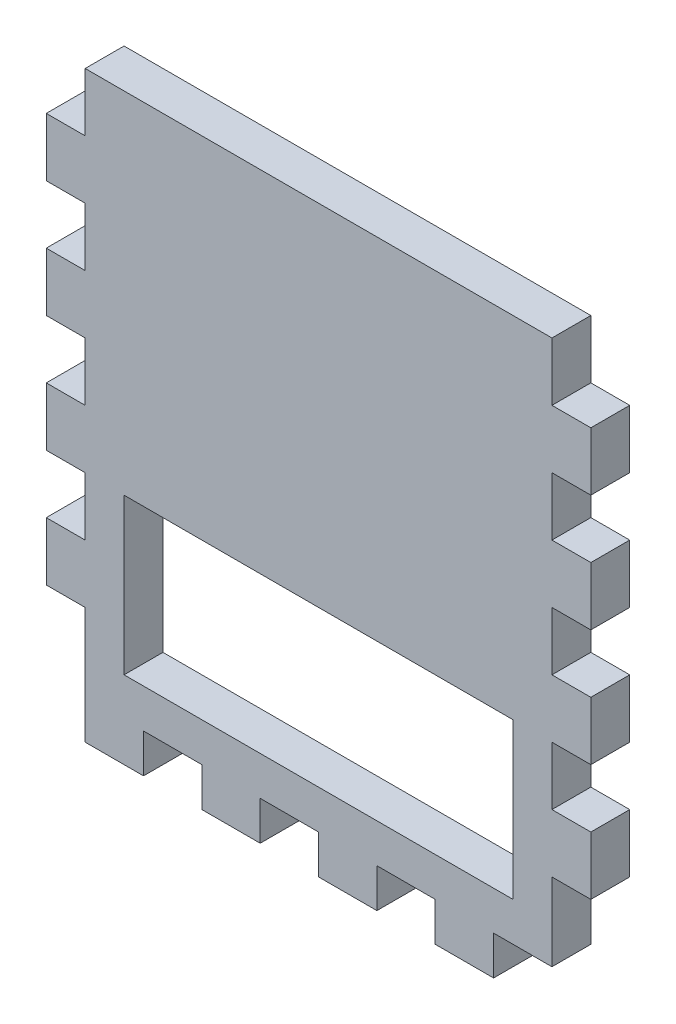
from build123d import *

# Parameters (mm, degrees)
SKETCH1_W           = 76.2
SKETCH1_H           = 88.9
SKETCH1_W_2         = 63.5
SKETCH1_H_2         = 25.4
BOSS_EXTRUDE1_DEPTH = 6.35
SKETCH2_W           = 6.35
SKETCH2_H           = 9.525
SKETCH2_W_2         = 9.525
SKETCH2_H_2         = 6.35
BOSS_EXTRUDE3_DEPTH = 6.35


with BuildPart() as part:
    # Sketch1 → Boss-Extrude1 (new body)
    with BuildSketch(Plane.XY):
        with Locations((38.1, -44.45)):
            Rectangle(SKETCH1_W, SKETCH1_H)
        with Locations((38.1, -69.85)):
            Rectangle(SKETCH1_W_2, SKETCH1_H_2, mode=Mode.SUBTRACT)
    extrude(amount=BOSS_EXTRUDE1_DEPTH)

    # Sketch2 → Boss-Extrude3 (add)
    with BuildSketch(Plane.XY.offset(6.35)):
        with Locations((-3.175, -14.2875)):
            Rectangle(SKETCH2_W, SKETCH2_H)
        with Locations((-3.175, -33.3375)):
            Rectangle(SKETCH2_W, SKETCH2_H)
        with Locations((-3.175, -52.3875)):
            Rectangle(SKETCH2_W, SKETCH2_H)
        with Locations((-3.175, -71.4375)):
            Rectangle(SKETCH2_W, SKETCH2_H)
        with Locations((4.7625, -92.075)):
            Rectangle(SKETCH2_W_2, SKETCH2_H_2)
        with Locations((23.8125, -92.075)):
            Rectangle(SKETCH2_W_2, SKETCH2_H_2)
        with Locations((79.375, -71.4375)):
            Rectangle(SKETCH2_W, SKETCH2_H)
        with Locations((79.375, -52.3875)):
            Rectangle(SKETCH2_W, SKETCH2_H)
        with Locations((79.375, -33.3375)):
            Rectangle(SKETCH2_W, SKETCH2_H)
        with Locations((79.375, -14.2875)):
            Rectangle(SKETCH2_W, SKETCH2_H)
        with Locations((42.8625, -92.075)):
            Rectangle(SKETCH2_W_2, SKETCH2_H_2)
        with Locations((61.9125, -92.075)):
            Rectangle(SKETCH2_W_2, SKETCH2_H_2)
    extrude(amount=-BOSS_EXTRUDE3_DEPTH)


solid = part.part
